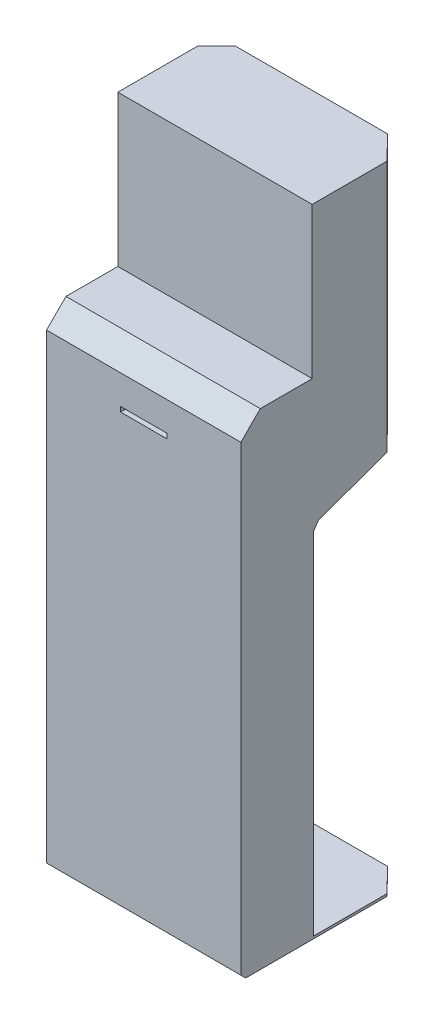
from build123d import *

# Parameters (mm, degrees)
BOSS_EXTRUDE1_DEPTH     = 400
CUT_EXTRUDE2_DEPTH      = 1
CUT_EXTRUDE2_DEPTH_BACK = 1311.69690242
SKETCH4_W               = 95
SKETCH4_H               = 10
CUT_EXTRUDE3_DEPTH      = 109


with BuildPart() as part:
    # Sketch1 → Boss-Extrude1 (new body)
    with BuildSketch(Plane(origin=(0, 0, 0), x_dir=(0, 0, -1), z_dir=(1, 0, 0))):
        Polygon((0, 0), (-340, 0), (-350, 10), (-350, 960), (-310, 1000), (-203.251091608, 1000), (-203.251091608, 1310.69690242), (-108.48888922, 1310.69690242), (0, 1310.69690242), (0, 1000), (0, 970), (0, 820), (-9.396926208, 806.579798567), (-27.474774195, 800), (-190.603073792, 740.62615458), (-200, 727.205953147), (-200, 5), (0, 5), align=None)
    extrude(amount=BOSS_EXTRUDE1_DEPTH)

    # Sketch3 → Cut-Extrude2 (cut, two sides)
    with BuildSketch(Plane(origin=(0, 0, 0), x_dir=(-1, 0, 0), z_dir=(0, -1, 0))) as cut_extrude2_sk:
        Polygon((32.971910004, -72.804395349), (-67.728153305, 29.569560354), (-322.648629759, 29.569560354), (-423.348693067, -72.804395349), (-423.348693067, 100.069531779), (32.971910004, 100.069531779), align=None)
    extrude(amount=CUT_EXTRUDE2_DEPTH, mode=Mode.SUBTRACT)
    extrude(cut_extrude2_sk.sketch, amount=-CUT_EXTRUDE2_DEPTH_BACK, mode=Mode.SUBTRACT)

    # Sketch4 → Cut-Extrude3 (cut)
    with BuildSketch(Plane.XY.offset(350)):
        with Locations((200, 895)):
            Rectangle(SKETCH4_W, SKETCH4_H)
    extrude(amount=-CUT_EXTRUDE3_DEPTH, mode=Mode.SUBTRACT)


solid = part.part
